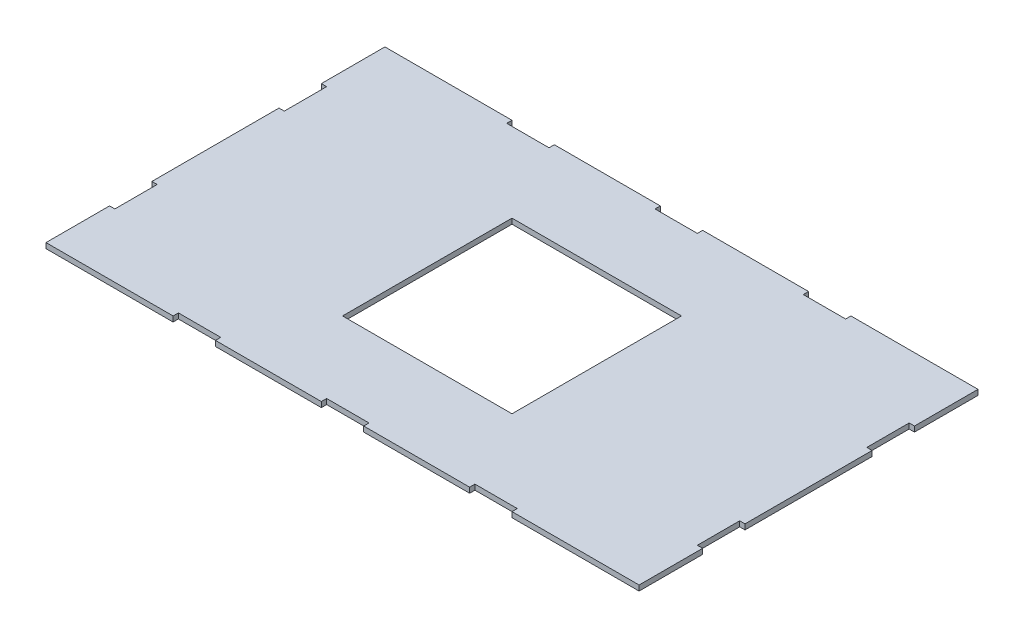
from build123d import *

# Parameters (mm, degrees)
SKETCH1_W           = 355.6
SKETCH1_H           = 203.2
BOSS_EXTRUDE1_DEPTH = 3.175
SKETCH2_W           = 101.6
SKETCH2_H           = 101.6
CUT_EXTRUDE1_DEPTH  = 4.175
SKETCH4_W           = 25.4
SKETCH4_H           = 3.175
SKETCH4_W_2         = 3.175
SKETCH4_H_2         = 25.4
CUT_EXTRUDE3_DEPTH  = 4.175


with BuildPart() as part:
    # Sketch1 → Boss-Extrude1 (new body)
    with BuildSketch(Plane(origin=(0, 0, 0), x_dir=(1, 0, 0), z_dir=(0, 1, 0))):
        with Locations((177.8, 101.6)):
            Rectangle(SKETCH1_W, SKETCH1_H)
    extrude(amount=BOSS_EXTRUDE1_DEPTH)

    # Sketch2 → Cut-Extrude1 (cut, through all)
    with BuildSketch(Plane(origin=(0, 3.175, 0), x_dir=(1, 0, 0), z_dir=(0, 1, 0))):
        with Locations((177.8, 101.6)):
            Rectangle(SKETCH2_W, SKETCH2_H)
    extrude(amount=-CUT_EXTRUDE1_DEPTH, mode=Mode.SUBTRACT)

    # Sketch4 → Cut-Extrude3 (cut, through all)
    with BuildSketch(Plane(origin=(0, 3.175, 0), x_dir=(1, 0, 0), z_dir=(0, 1, 0))):
        with Locations((88.9, 1.5875)):
            Rectangle(SKETCH4_W, SKETCH4_H)
        with Locations((177.8, 1.5875)):
            Rectangle(SKETCH4_W, SKETCH4_H)
        with Locations((266.7, 1.5875)):
            Rectangle(SKETCH4_W, SKETCH4_H)
        with Locations((266.7, 201.6125)):
            Rectangle(SKETCH4_W, SKETCH4_H)
        with Locations((177.8, 201.6125)):
            Rectangle(SKETCH4_W, SKETCH4_H)
        with Locations((88.9, 201.6125)):
            Rectangle(SKETCH4_W, SKETCH4_H)
        with Locations((1.5875, 152.4)):
            Rectangle(SKETCH4_W_2, SKETCH4_H_2)
        with Locations((1.5875, 50.8)):
            Rectangle(SKETCH4_W_2, SKETCH4_H_2)
        with Locations((354.0125, 50.8)):
            Rectangle(SKETCH4_W_2, SKETCH4_H_2)
        with Locations((354.0125, 152.4)):
            Rectangle(SKETCH4_W_2, SKETCH4_H_2)
    extrude(amount=-CUT_EXTRUDE3_DEPTH, mode=Mode.SUBTRACT)


solid = part.part
